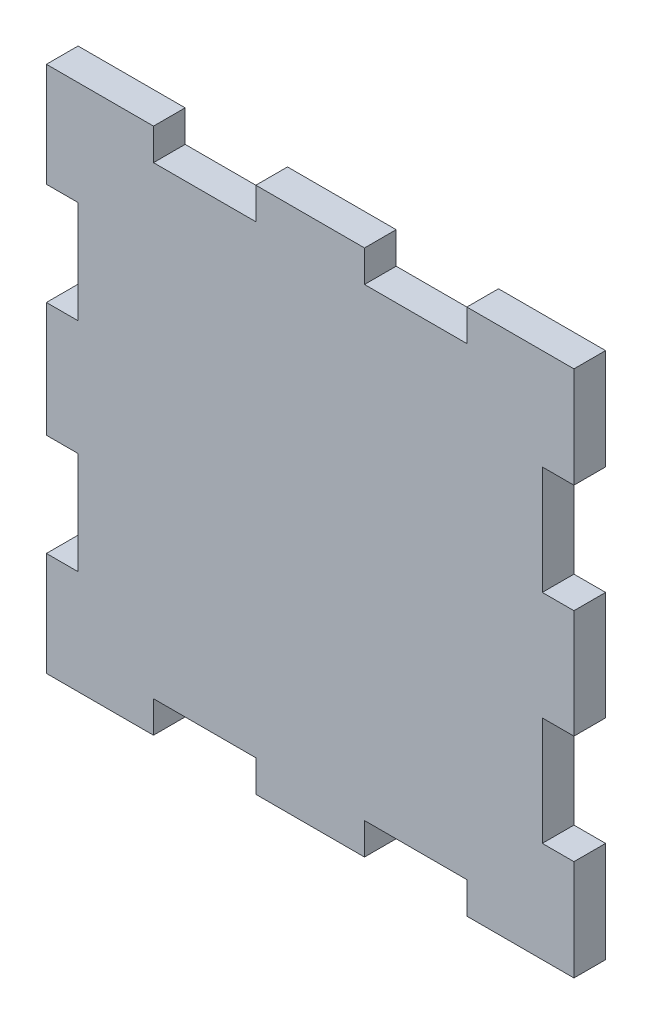
from build123d import *

# Parameters (mm, degrees)
SALIENTE_EXTRUIR1_DEPTH = 3


with BuildPart() as part:
    # Croquis1 → Saliente-Extruir1 (new body)
    with BuildSketch(Plane.XY):
        Polygon((-25, -25), (-14.85, -25), (-14.85, -22), (-5.15, -22), (-5.15, -25), (5.15, -25), (5.15, -22), (14.85, -22), (14.85, -25), (25, -25), (25, -15.45), (22, -15.45), (22, -5.15), (25, -5.15), (25, 5.15), (22, 5.15), (22, 15.45), (25, 15.45), (25, 25), (14.85, 25), (14.85, 22), (5.15, 22), (5.15, 25), (-5.15, 25), (-5.15, 22), (-14.85, 22), (-14.85, 25), (-25, 25), (-25, 15.15), (-22, 15.15), (-22, 5.45), (-25, 5.45), (-25, -5.45), (-22, -5.45), (-22, -15.15), (-25, -15.15), align=None)
    extrude(amount=SALIENTE_EXTRUIR1_DEPTH)


solid = part.part
